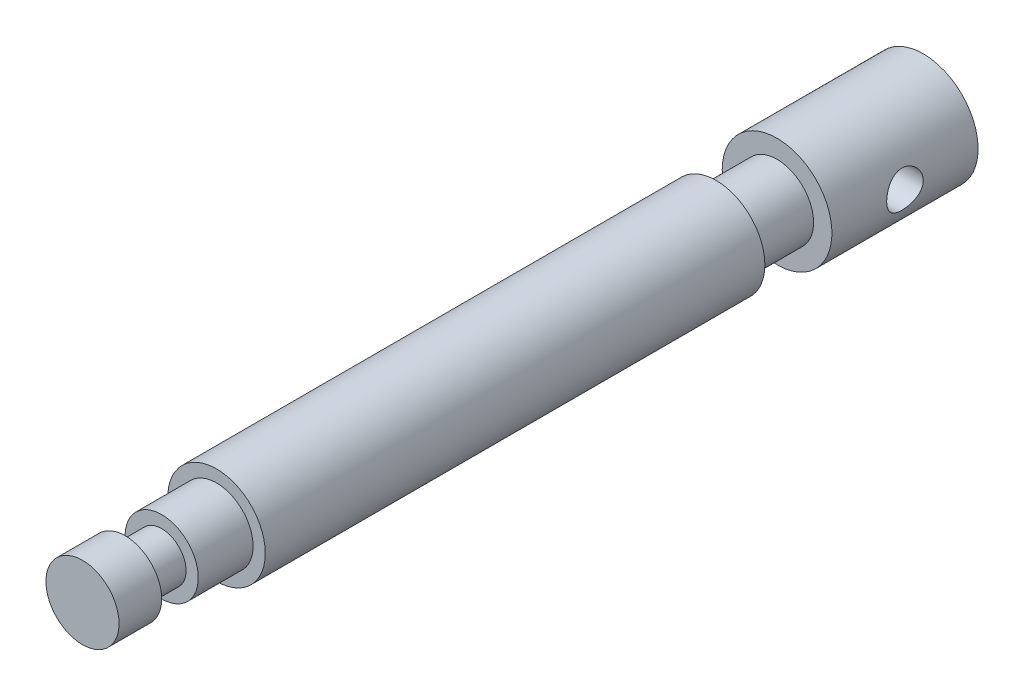
from build123d import *

# Parameters (mm, degrees)
SKETCH4_R           = 8
BOSS_EXTRUDE2_DEPTH = 41
SKETCH5_R           = 6
BOSS_EXTRUDE3_DEPTH = 10
SKETCH6_R           = 9
BOSS_EXTRUDE4_DEPTH = 24
SKETCH7_R           = 6
BOSS_EXTRUDE5_DEPTH = 9
SKETCH8_R           = 4
BOSS_EXTRUDE6_DEPTH = 6
SKETCH9_R           = 6
BOSS_EXTRUDE7_DEPTH = 7
SKETCH10_R          = 3
CUT_EXTRUDE1_DEPTH  = 25


with BuildPart() as part:
    # Sketch4 → Boss-Extrude2 (new body, symmetric)
    with BuildSketch(Plane.XY):
        Circle(SKETCH4_R)
    extrude(amount=BOSS_EXTRUDE2_DEPTH, both=True)

    # Sketch5 → Boss-Extrude3 (add)
    with BuildSketch(Plane(origin=(0, 0, -41), x_dir=(-1, 0, 0), z_dir=(0, 0, -1))):
        Circle(SKETCH5_R)
    extrude(amount=BOSS_EXTRUDE3_DEPTH)

    # Sketch6 → Boss-Extrude4 (add)
    with BuildSketch(Plane(origin=(0, 0, -51), x_dir=(-1, 0, 0), z_dir=(0, 0, -1))):
        Circle(SKETCH6_R)
    extrude(amount=BOSS_EXTRUDE4_DEPTH)

    # Sketch7 → Boss-Extrude5 (add)
    with BuildSketch(Plane.XY.offset(41)):
        Circle(SKETCH7_R)
    extrude(amount=BOSS_EXTRUDE5_DEPTH)

    # Sketch8 → Boss-Extrude6 (add)
    with BuildSketch(Plane.XY.offset(50)):
        Circle(SKETCH8_R)
    extrude(amount=BOSS_EXTRUDE6_DEPTH)

    # Sketch9 → Boss-Extrude7 (add)
    with BuildSketch(Plane.XY.offset(56)):
        Circle(SKETCH9_R)
    extrude(amount=BOSS_EXTRUDE7_DEPTH)

    # Sketch10 → Cut-Extrude1 (cut, symmetric)
    with BuildSketch(Plane(origin=(0, 0, 0), x_dir=(0, 0, -1), z_dir=(1, 0, 0))):
        with Locations((63, 0)):
            Circle(SKETCH10_R)
    extrude(amount=CUT_EXTRUDE1_DEPTH, both=True, mode=Mode.SUBTRACT)


solid = part.part
